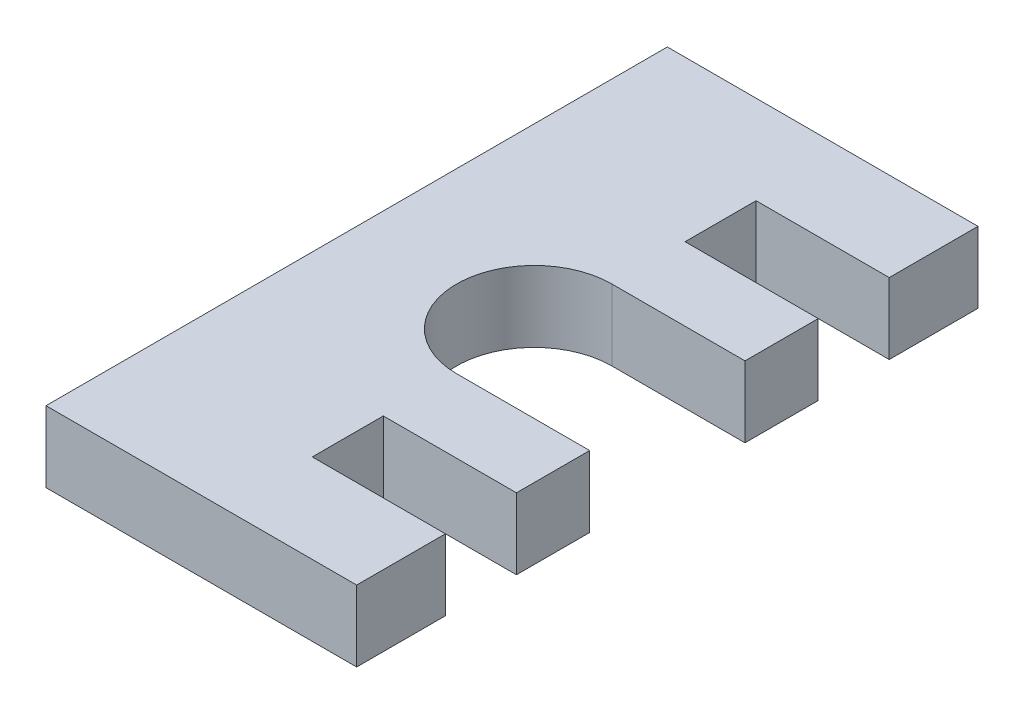
from build123d import *

# Parameters (mm, degrees)
BOSS_EXTRUDE1_DEPTH = 5.08


with BuildPart() as part:
    # Sketch1 → Boss-Extrude1 (new body)
    with BuildSketch(Plane(origin=(0, 0, 0), x_dir=(1, 0, 0), z_dir=(0, 1, 0))):
        with BuildLine():
            Line((22.225, 22.225), (22.225, 15.875))
            Line((22.225, 15.875), (12.7, 15.875))
            Line((12.7, 15.875), (12.7, 10.795))
            Line((12.7, 10.795), (22.225, 10.795))
            Line((22.225, 10.795), (22.225, 5.55625))
            Line((22.225, 5.55625), (12.7, 5.55625))
            ThreePointArc((12.7, 5.55625), (7.14375, 0), (12.7, -5.55625))
            Line((12.7, -5.55625), (22.225, -5.55625))
            Line((22.225, -5.55625), (22.225, -10.795))
            Line((22.225, -10.795), (12.7, -10.795))
            Line((12.7, -10.795), (12.7, -15.875))
            Line((12.7, -15.875), (22.225, -15.875))
            Line((22.225, -15.875), (22.225, -22.225))
            Line((22.225, -22.225), (0, -22.225))
            Line((0, -22.225), (0, 0))
            Line((0, 0), (0, 22.225))
            Line((0, 22.225), (22.225, 22.225))
        make_face()
    extrude(amount=BOSS_EXTRUDE1_DEPTH)


solid = part.part
